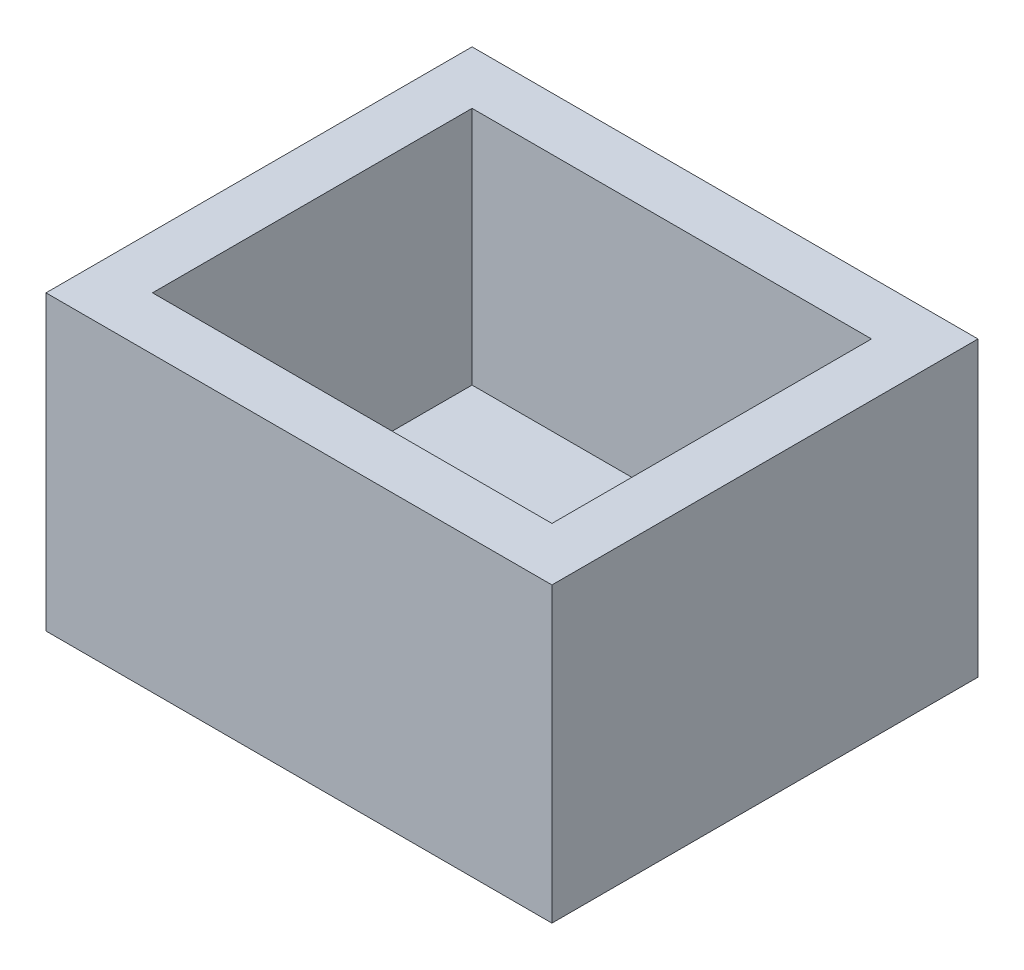
from build123d import *

# Parameters (mm, degrees)
SKETCH1_W           = 19
SKETCH1_H           = 16
BOSS_EXTRUDE1_DEPTH = 11
SHELL1_T            = -2
SKETCH2_R           = 0.625
CUT_EXTRUDE1_DEPTH  = 10


with BuildPart() as part:
    # Sketch1 → Boss-Extrude1 (new body)
    with BuildSketch(Plane(origin=(0, 0, 0), x_dir=(1, 0, 0), z_dir=(0, 1, 0))):
        with Locations((9.5, 8)):
            Rectangle(SKETCH1_W, SKETCH1_H)
    extrude(amount=BOSS_EXTRUDE1_DEPTH)

    # Shell1
    shell1_openings = [part.faces().sort_by_distance(p)[0] for p in [
        (9.5, 11, -8),
    ]]
    offset(amount=SHELL1_T, openings=shell1_openings, kind=Kind.INTERSECTION)

    # Sketch2 → Cut-Extrude1 (cut)
    with BuildSketch(Plane(origin=(0, 2, 0), x_dir=(1, 0, 0), z_dir=(0, 1, 0))):
        with Locations((16.025684832, 11.778007382)):
            Circle(SKETCH2_R)
        with Locations((16.025684832, 6.698007382)):
            Circle(SKETCH2_R)
        with Locations((16.025684832, 4.158007382)):
            Circle(SKETCH2_R)
    extrude(amount=-CUT_EXTRUDE1_DEPTH, mode=Mode.SUBTRACT)


solid = part.part
